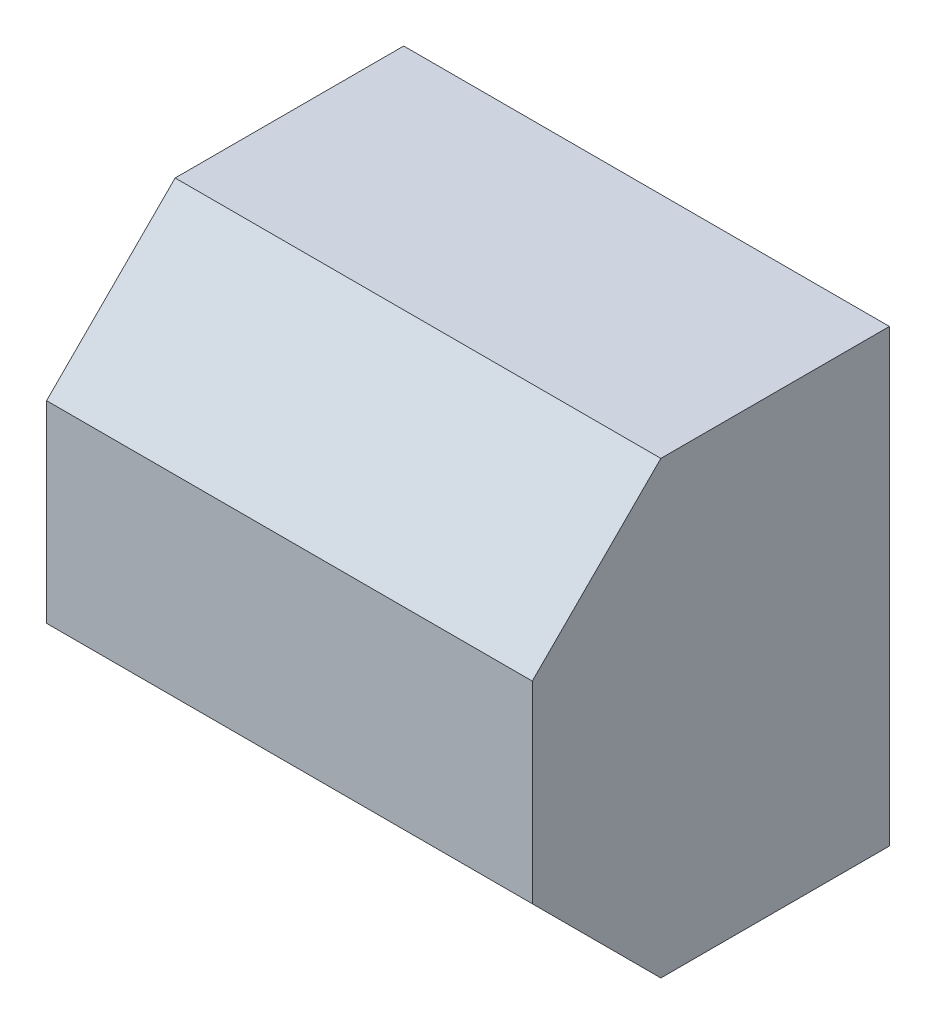
from build123d import *

# Parameters (mm, degrees)
SKETCH_1_W      = 6.8
SKETCH_1_H      = 6.3
EXTRUDE_1_DEPTH = 5
CHAMFER_1_SIZE  = 1.8


with BuildPart() as part:
    # 草图1 → 凸台-拉伸1 (new body)
    with BuildSketch(Plane.XY):
        with Locations((-2.131657577, -0.555911138)):
            Rectangle(SKETCH_1_W, SKETCH_1_H)
    extrude(amount=EXTRUDE_1_DEPTH)

    # 倒角1
    chamfer_1_edges = [part.edges().sort_by_distance(p)[0] for p in [
        (-2.131657577, 2.594088862, 5),
        (-2.131657577, -3.705911138, 5),
    ]]
    chamfer(chamfer_1_edges, length=CHAMFER_1_SIZE)


solid = part.part
